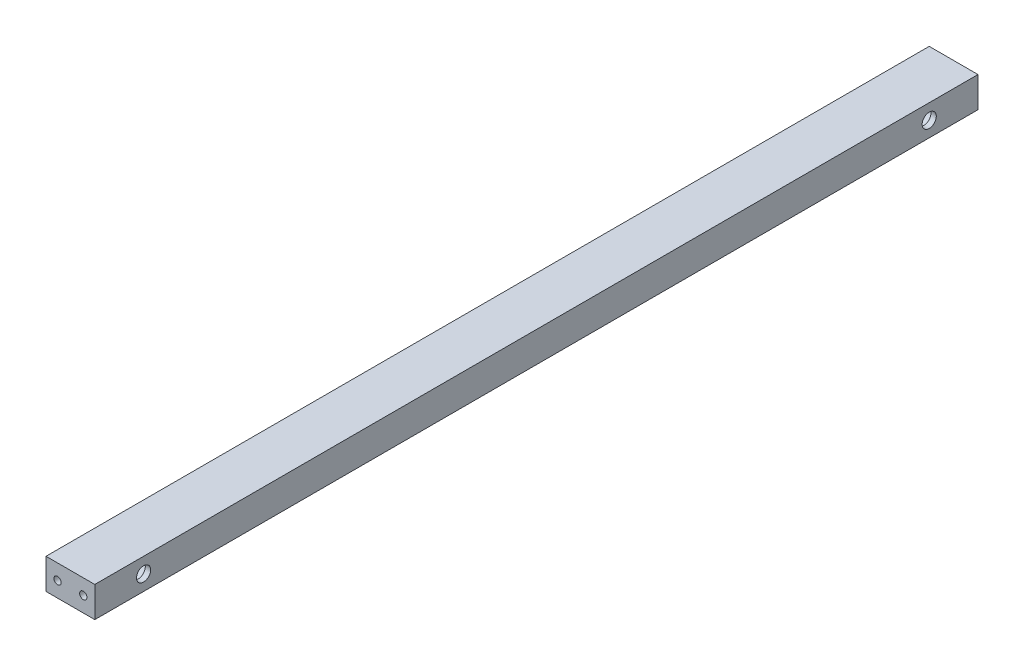
from build123d import *

# Parameters (mm, degrees)
SKETCH1_W                      = 25.4
SKETCH1_H                      = 15.875
BOSS_EXTRUDE1_DEPTH            = 459.74
SKETCH8_R                      = 6.8199
CUT_EXTRUDE1_DEPTH             = 22.61362
L_0_29_DIAMETER_HOLE1_D        = 7.366
L_0_29_DIAMETER_HOLE1_DEPTH    = 50.8
L_0_29_DIAMETER_HOLE1_TIP      = 2.21296966
TAP_DRILL_FOR_10_24_TAP2_D     = 3.7973
TAP_DRILL_FOR_10_24_TAP2_DEPTH = 20.701
TAP_DRILL_FOR_10_24_TAP2_TIP   = 1.140824014
TAP_DRILL_FOR_10_24_TAP1_D     = 3.7973
TAP_DRILL_FOR_10_24_TAP1_DEPTH = 20.701
TAP_DRILL_FOR_10_24_TAP1_TIP   = 1.140824014


with BuildPart() as part:
    # Sketch1 → Boss-Extrude1 (new body)
    with BuildSketch(Plane.XY):
        with Locations((12.7, 7.9375)):
            Rectangle(SKETCH1_W, SKETCH1_H)
    extrude(amount=BOSS_EXTRUDE1_DEPTH)

    # Sketch8 → Cut-Extrude1 (cut)
    with BuildSketch(Plane.ZY):
        with Locations((434.34, 7.9375)):
            Circle(SKETCH8_R)
        with Locations((25.4, 7.9375)):
            Circle(SKETCH8_R)
    extrude(amount=-CUT_EXTRUDE1_DEPTH, mode=Mode.SUBTRACT)

    # L (0.29) Diameter Hole1
    with Locations(Plane.ZY.offset(-22.61362)):
        with Locations((25.4, 7.9375), (434.34, 7.9375)):
            Hole(L_0_29_DIAMETER_HOLE1_D / 2, depth=L_0_29_DIAMETER_HOLE1_DEPTH)
            with Locations((0, 0, -(L_0_29_DIAMETER_HOLE1_DEPTH + L_0_29_DIAMETER_HOLE1_TIP / 2))):  # 118° drill point
                Cone(0, L_0_29_DIAMETER_HOLE1_D / 2, L_0_29_DIAMETER_HOLE1_TIP, mode=Mode.SUBTRACT)

    # Tap Drill for #10-24 Tap2
    with Locations(Plane(origin=(-2202.638131805, 879.599136144, 459.74), x_dir=(0, 1, 0), z_dir=(0, 0, 1))):
        with Locations((-871.661636144, -2222.038131805), (-871.661636144, -2208.638131805)):
            Hole(TAP_DRILL_FOR_10_24_TAP2_D / 2, depth=TAP_DRILL_FOR_10_24_TAP2_DEPTH)
            with Locations((0, 0, -(TAP_DRILL_FOR_10_24_TAP2_DEPTH + TAP_DRILL_FOR_10_24_TAP2_TIP / 2))):  # 118° drill point
                Cone(0, TAP_DRILL_FOR_10_24_TAP2_D / 2, TAP_DRILL_FOR_10_24_TAP2_TIP, mode=Mode.SUBTRACT)

    # Tap Drill for #10-24 Tap1
    with Locations(Plane(origin=(0, 0, 0), x_dir=(-1, 0, 0), z_dir=(0, 0, -1))):
        with Locations((-19.4, 7.9375), (-6, 7.9375)):
            Hole(TAP_DRILL_FOR_10_24_TAP1_D / 2, depth=TAP_DRILL_FOR_10_24_TAP1_DEPTH)
            with Locations((0, 0, -(TAP_DRILL_FOR_10_24_TAP1_DEPTH + TAP_DRILL_FOR_10_24_TAP1_TIP / 2))):  # 118° drill point
                Cone(0, TAP_DRILL_FOR_10_24_TAP1_D / 2, TAP_DRILL_FOR_10_24_TAP1_TIP, mode=Mode.SUBTRACT)


solid = part.part
